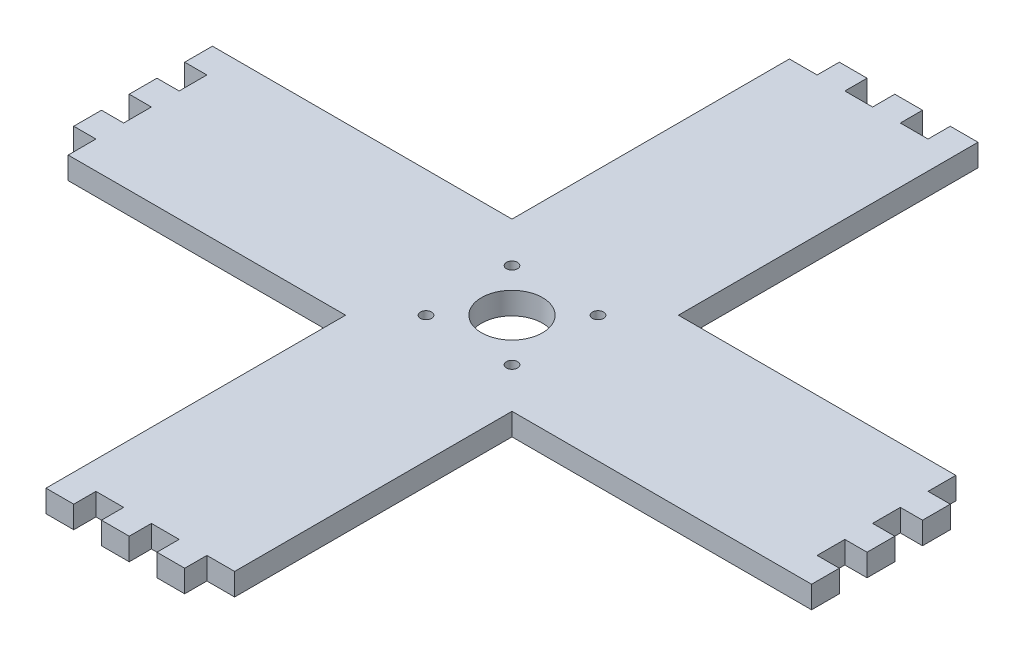
from build123d import *

# Parameters (mm, degrees)
SKETCH_1_R      = 11
SKETCH_1_R_2    = 2
EXTRUDE_1_DEPTH = 8


with BuildPart() as part:
    # 草图1 → 凸台-拉伸1 (new body)
    with BuildSketch(Plane(origin=(0, 0, 0), x_dir=(1, 0, 0), z_dir=(0, 1, 0))):
        Polygon((-130, -30), (-30, -30), (-30, -138), (-20, -138), (-20, -130), (-10, -130), (-10, -138), (0, -138), (0, -130), (10, -130), (10, -138), (20, -138), (20, -130), (30, -130), (30, -30), (138, -30), (138, -20), (130, -20), (130, -10), (138, -10), (138, 0), (130, 0), (130, 10), (138, 10), (138, 20), (130, 20), (130, 30), (30, 30), (30, 138), (20, 138), (20, 130), (10, 130), (10, 138), (0, 138), (0, 130), (-10, 130), (-10, 138), (-20, 138), (-20, 130), (-30, 130), (-30, 30), (-138, 30), (-138, 20), (-130, 20), (-130, 10), (-138, 10), (-138, 0), (-130, 0), (-130, -10), (-138, -10), (-138, -20), (-130, -20), align=None)
        Circle(SKETCH_1_R, mode=Mode.SUBTRACT)
        with Locations((-15.5, 15.5)):
            Circle(SKETCH_1_R_2, mode=Mode.SUBTRACT)
        with Locations((15.5, 15.5)):
            Circle(SKETCH_1_R_2, mode=Mode.SUBTRACT)
        with Locations((-15.5, -15.5)):
            Circle(SKETCH_1_R_2, mode=Mode.SUBTRACT)
        with Locations((15.5, -15.5)):
            Circle(SKETCH_1_R_2, mode=Mode.SUBTRACT)
    extrude(amount=EXTRUDE_1_DEPTH)


solid = part.part
